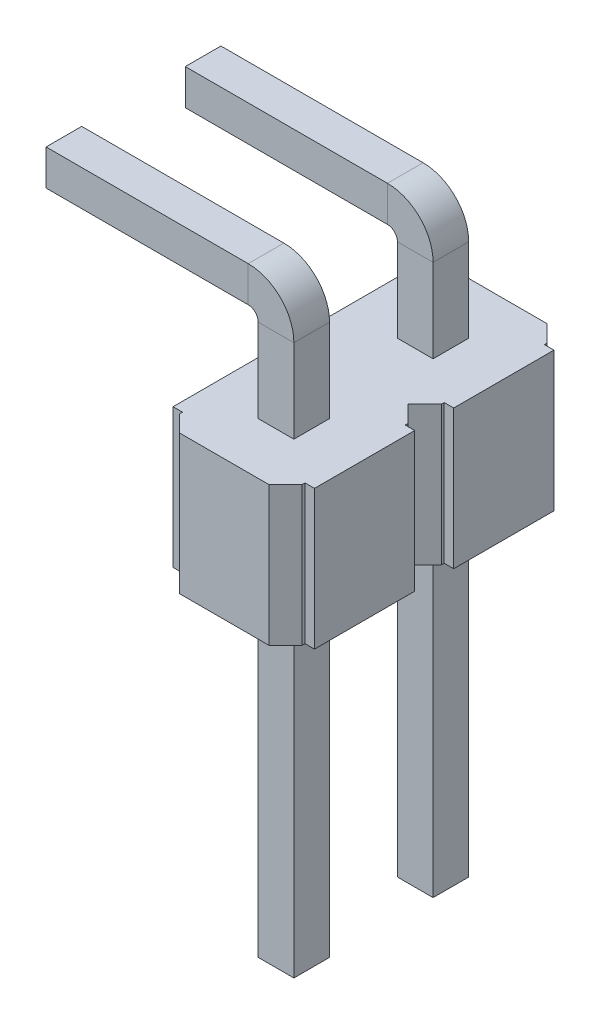
from build123d import *

# Parameters (mm, degrees)
BOSS_EXTRUDE1_DEPTH        = 2.5
SKETCH6_W                  = 0.64
SKETCH6_H                  = 0.64
CUT_EXTRUDE1_DEPTH         = 2.5
SKETCH15_W                 = 0.64
SKETCH15_H                 = 0.64
CHAMFER4_SIZE              = 0.12
LPATTERN5_COUNT            = 2
LPATTERN5_PITCH            = 2.5
CHAMFER4_OF_LPATTERN5_SIZE = 0.12


with BuildPart() as part:
    # Sketch4 → Boss-Extrude1 (new body)
    with BuildSketch(Plane(origin=(0, 0, 0), x_dir=(1, 0, 0), z_dir=(0, 1, 0))):
        Polygon((-2.37, -0.9), (-2.37, -0.95), (-2.07, -1.25), (-0.47, -1.25), (-0.17, -0.95), (-0.17, -0.9), (0, -0.9), (0, 0.9), (-0.17, 0.9), (-0.17, 0.95), (-0.47, 1.25), (-2.07, 1.25), (-2.37, 0.95), (-2.37, 0.9), (-2.54, 0.9), (-2.54, -0.9), align=None)
    boss_extrude1 = extrude(amount=BOSS_EXTRUDE1_DEPTH)

    # Sketch6 → Cut-Extrude1 (cut)
    with BuildSketch(Plane.XZ):
        with Locations((-1.27, 0)):
            Rectangle(SKETCH6_W, SKETCH6_H)
        with Locations((1.27, 0)):
            Rectangle(SKETCH6_W, SKETCH6_H)
    extrude(amount=-CUT_EXTRUDE1_DEPTH, mode=Mode.SUBTRACT)

    # Sweep1: sweep along a path in Sketch17
    with BuildLine(Plane(origin=(0, 0, 0), x_dir=(1, 0, 0), z_dir=(0, 0, -1))) as sweep1_path:
        Line((-1.27, 6), (-1.27, -4))
        ThreePointArc((-1.27, -4), (-1.416446609, -4.353553391), (-1.77, -4.5))
        Line((-1.77, -4.5), (-5.52, -4.5))
    # Sketch15 → Sweep1 (sweep)
    with BuildSketch(Plane(origin=(0, -6, 0), x_dir=(1, 0, 0), z_dir=(0, 1, 0))):
        with Locations((-1.27, 0)):
            Rectangle(SKETCH15_W, SKETCH15_H)
    sweep1 = sweep(path=sweep1_path.line)

    # Chamfer4
    chamfer4_edges = [part.edges().sort_by_distance(p)[0] for p in [
        (-0.95, -6, 0),
        (-1.59, -6, 0),
        (-1.27, -6, -0.32),
        (-1.27, -6, 0.32),
        (-5.52, 4.18, 0),
        (-5.52, 4.5, 0.32),
        (-5.52, 4.82, 0),
        (-5.52, 4.5, -0.32),
    ]]
    chamfer(chamfer4_edges, length=CHAMFER4_SIZE)

    # LPattern5: Boss-Extrude1, Sweep1 ×2
    with Locations(*[(0, 0, i * LPATTERN5_PITCH) for i in range(1, LPATTERN5_COUNT)]):
        add(boss_extrude1)
        add(sweep1)

    # Chamfer4 of LPattern5
    chamfer4_of_lpattern5_edges = [part.edges().sort_by_distance(p)[0] for p in [
        (-0.95, -6, 2.5),
        (-1.59, -6, 2.5),
        (-1.27, -6, 2.18),
        (-1.27, -6, 2.82),
        (-5.52, 4.18, 2.5),
        (-5.52, 4.5, 2.82),
        (-5.52, 4.82, 2.5),
        (-5.52, 4.5, 2.18),
    ]]
    chamfer(chamfer4_of_lpattern5_edges, length=CHAMFER4_OF_LPATTERN5_SIZE)


solid = part.part
